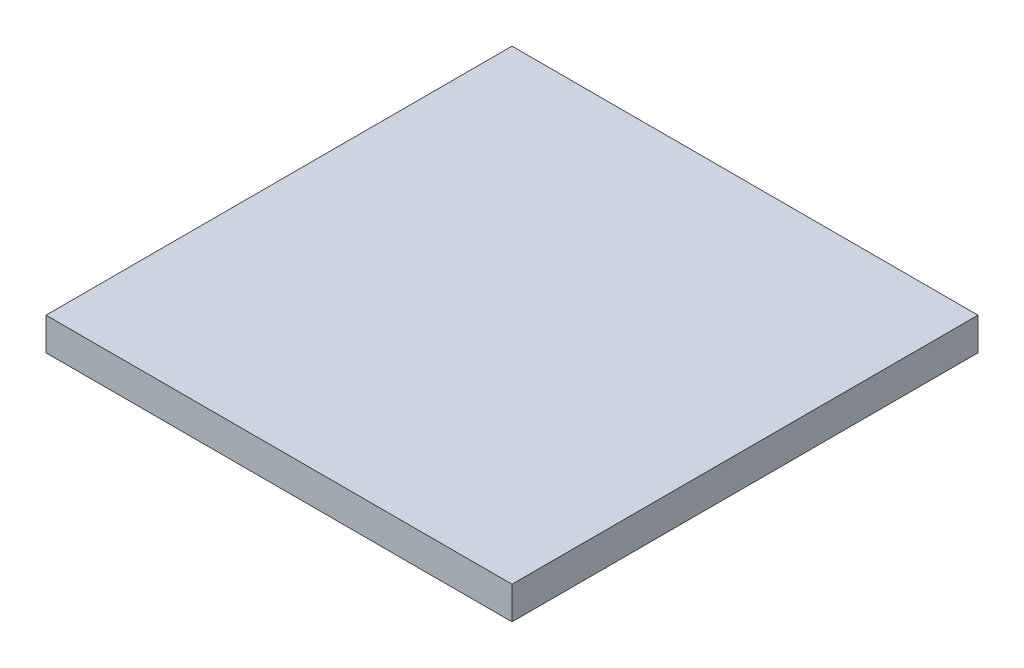
from build123d import *

# Parameters (mm, degrees)
ESQUISSE1_W        = 500
ESQUISSE1_H        = 500
BOSS_EXTRU_1_DEPTH = 35


with BuildPart() as part:
    # Esquisse1 → Boss.-Extru.1 (new body)
    with BuildSketch(Plane(origin=(0, 0, 0), x_dir=(1, 0, 0), z_dir=(0, 1, 0))):
        Rectangle(ESQUISSE1_W, ESQUISSE1_H)
    extrude(amount=-BOSS_EXTRU_1_DEPTH)


solid = part.part
